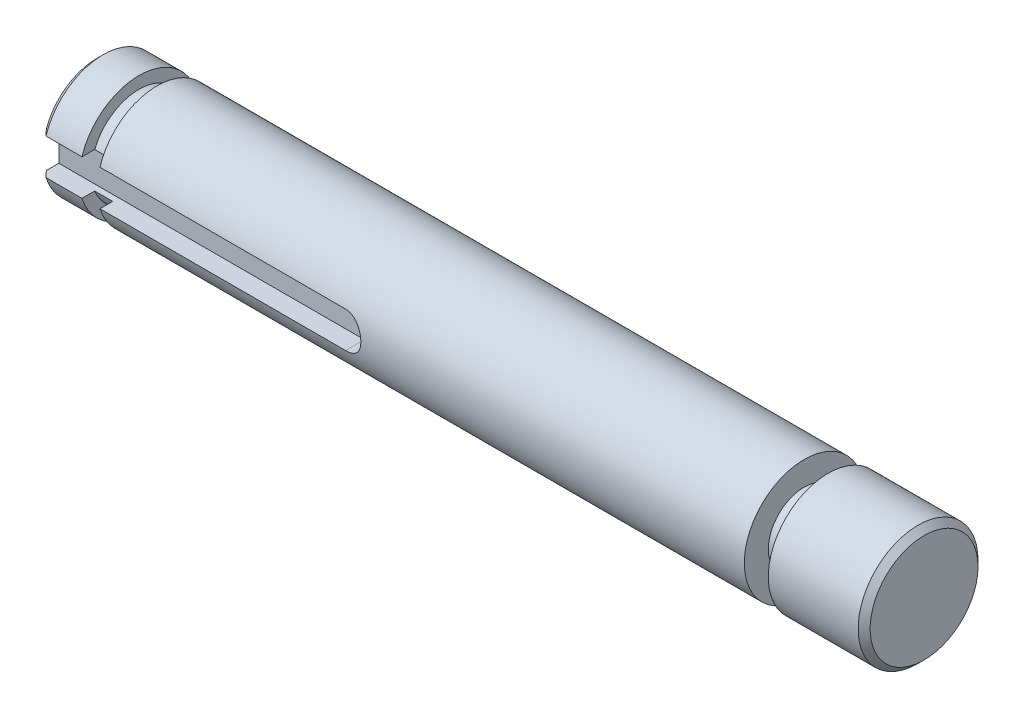
from build123d import *

# Parameters (mm, degrees)
SKETCH1_R           = 5
BOSS_EXTRUDE1_DEPTH = 34.5
CUT_EXTRUDE1_START  = -10
SKETCH2_R           = 5
SKETCH2_R_2         = 3
CUT_EXTRUDE1_DEPTH  = 2
CUT_EXTRUDE2_START  = -5
SKETCH3_R           = 5
SKETCH3_R_2         = 4
CUT_EXTRUDE2_DEPTH  = 1.5
CHAMFER1_SIZE       = 0.5
CUT_EXTRUDE3_START  = 3.2
CUT_EXTRUDE3_DEPTH  = 2.8


with BuildPart() as part:
    # Sketch1 → Boss-Extrude1 (new body, symmetric)
    with BuildSketch(Plane(origin=(0, 0, 0), x_dir=(0, 0, -1), z_dir=(1, 0, 0))):
        Circle(SKETCH1_R)
    extrude(amount=BOSS_EXTRUDE1_DEPTH, both=True)

    # Sketch2 → Cut-Extrude1 (cut)
    with BuildSketch(Plane(origin=(34.5, 0, 0), x_dir=(0, 0, -1), z_dir=(1, 0, 0)).offset(CUT_EXTRUDE1_START)):
        Circle(SKETCH2_R)
        Circle(SKETCH2_R_2, mode=Mode.SUBTRACT)
    extrude(amount=CUT_EXTRUDE1_DEPTH, mode=Mode.SUBTRACT)

    # Sketch3 → Cut-Extrude2 (cut)
    with BuildSketch(Plane.ZY.offset(34.5).offset(CUT_EXTRUDE2_START)):
        Circle(SKETCH3_R)
        Circle(SKETCH3_R_2, mode=Mode.SUBTRACT)
    extrude(amount=CUT_EXTRUDE2_DEPTH, mode=Mode.SUBTRACT)

    # Chamfer1
    chamfer1_edges = [part.edges().sort_by_distance(p)[0] for p in [
        (-34.5, 0, 5),
        (34.5, 0, 5),
    ]]
    chamfer(chamfer1_edges, length=CHAMFER1_SIZE)

    # Sketch4 → Cut-Extrude3 (cut, through all)
    with BuildSketch(Plane.XY.offset(CUT_EXTRUDE3_START)):
        with BuildLine():
            Line((-34.5, 1.5), (-9, 1.5))
            ThreePointArc((-9, 1.5), (-7.5, 0), (-9, -1.5))
            Line((-9, -1.5), (-34.5, -1.5))
            Line((-34.5, -1.5), (-34.5, 1.5))
        make_face()
    extrude(amount=CUT_EXTRUDE3_DEPTH, mode=Mode.SUBTRACT)


solid = part.part
